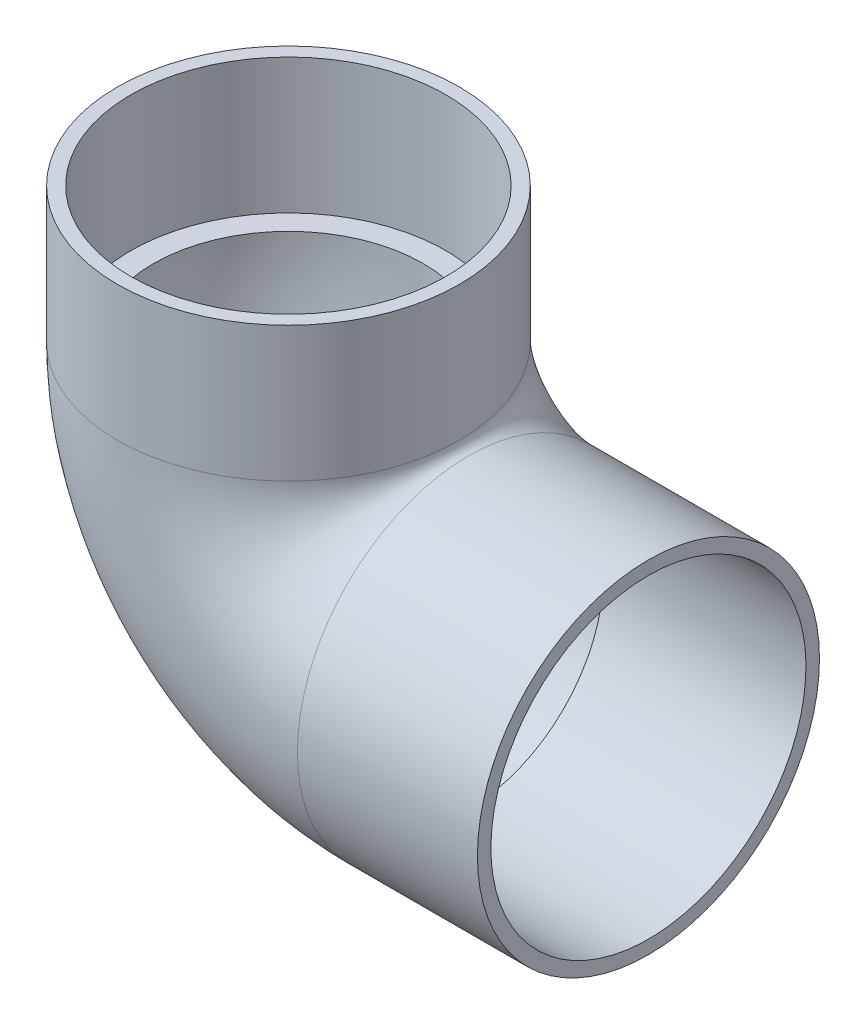
from build123d import *

# Parameters (mm, degrees)
SKETCH2_R          = 48.26
SKETCH2_R_2        = 38.1
SKETCH3_R          = 44.45
SKETCH3_R_2        = 38.1
CUT_EXTRUDE1_DEPTH = 57.15
SKETCH4_R          = 44.45
SKETCH4_R_2        = 38.1
CUT_EXTRUDE2_DEPTH = 38.1


with BuildPart() as part:
    # Sweep1: sweep along a path in Sketch1
    with BuildLine(Plane.XY) as sweep1_path:
        Line((0, 88.9), (0, 50.8))
        ThreePointArc((0, 50.8), (14.878975516, 14.878975516), (50.8, 0))
        Line((50.8, 0), (101.6, 0))
    # Sketch2 → Sweep1 (sweep)
    with BuildSketch(Plane(origin=(0, 88.9, 0), x_dir=(1, 0, 0), z_dir=(0, 1, 0))):
        Circle(SKETCH2_R)
        Circle(SKETCH2_R_2, mode=Mode.SUBTRACT)
    sweep(path=sweep1_path.line)

    # Sketch3 → Cut-Extrude1 (cut)
    with BuildSketch(Plane(origin=(101.6, 0, 0), x_dir=(0, 0, -1), z_dir=(1, 0, 0))):
        Circle(SKETCH3_R)
        Circle(SKETCH3_R_2, mode=Mode.SUBTRACT)
    extrude(amount=-CUT_EXTRUDE1_DEPTH, mode=Mode.SUBTRACT)

    # Sketch4 → Cut-Extrude2 (cut)
    with BuildSketch(Plane(origin=(0, 88.9, 0), x_dir=(1, 0, 0), z_dir=(0, 1, 0))):
        Circle(SKETCH4_R)
        Circle(SKETCH4_R_2, mode=Mode.SUBTRACT)
    extrude(amount=-CUT_EXTRUDE2_DEPTH, mode=Mode.SUBTRACT)


solid = part.part
